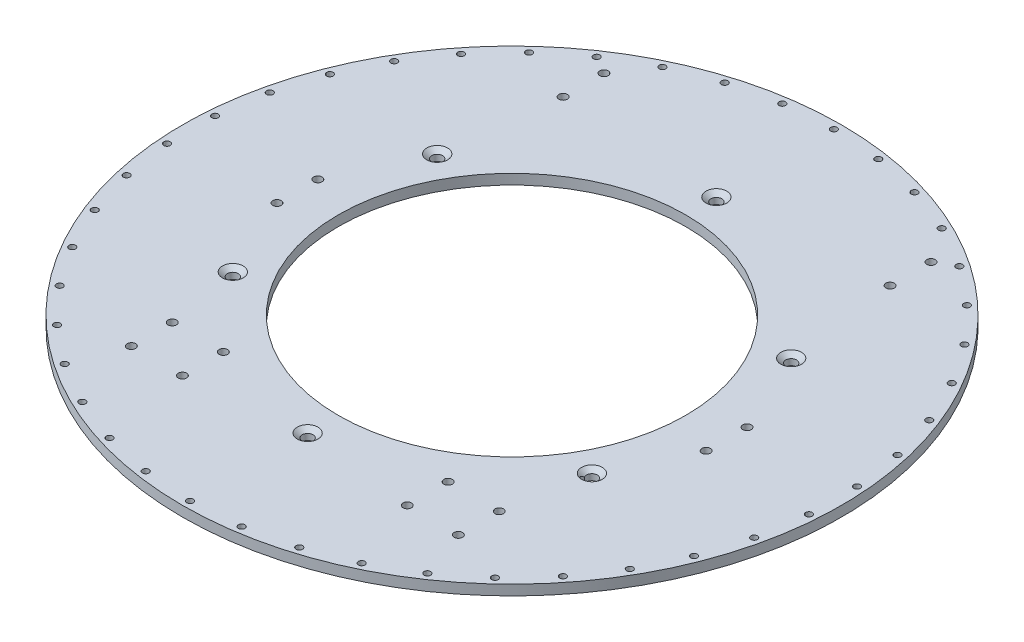
from build123d import *

# Parameters (mm, degrees)
SKETCH1_R                                           = 196.85
SKETCH1_R_2                                         = 107.95
SKETCH1_R_3                                         = 2.6289
SKETCH1_R_4                                         = 3.175
BOSS_EXTRUDE1_DEPTH                                 = 6.35
SKETCH3_R                                           = 204.7875
SKETCH3_R_2                                         = 196.85
BOSS_EXTRUDE2_DEPTH                                 = 6.35
CSK_FOR_1_4_FLAT_HEAD_MACHINE_SCREW_100_D           = 6.7564
CSK_FOR_1_4_FLAT_HEAD_MACHINE_SCREW_100_DEPTH       = 25.4
CSK_FOR_1_4_FLAT_HEAD_MACHINE_SCREW_100_CSINK_D     = 12.8778
CSK_FOR_1_4_FLAT_HEAD_MACHINE_SCREW_100_CSINK_ANGLE = 100
CSK_FOR_1_4_FLAT_HEAD_MACHINE_SCREW_100_TIP         = 2.029827343
SKETCH10_R                                          = 2.0193
CUT_EXTRUDE1_DEPTH                                  = 7.3500001


with BuildPart() as part:
    # Sketch1 → Boss-Extrude1 (new body)
    with BuildSketch(Plane(origin=(0, 0, 0), x_dir=(1, 0, 0), z_dir=(0, 1, 0))):
        Circle(SKETCH1_R)
        Circle(SKETCH1_R_2, mode=Mode.SUBTRACT)
        with Locations((69.85, -109.5375)):
            Circle(SKETCH1_R_3, mode=Mode.SUBTRACT)
        with Locations((69.85, -134.9375)):
            Circle(SKETCH1_R_3, mode=Mode.SUBTRACT)
        with Locations((101.6, -109.5375)):
            Circle(SKETCH1_R_3, mode=Mode.SUBTRACT)
        with Locations((101.6, -134.9375)):
            Circle(SKETCH1_R_3, mode=Mode.SUBTRACT)
        with Locations((101.6, 133.35)):
            Circle(SKETCH1_R_3, mode=Mode.SUBTRACT)
        with Locations((101.6, 158.75)):
            Circle(SKETCH1_R_3, mode=Mode.SUBTRACT)
        with Locations((133.35, -12.7)):
            Circle(SKETCH1_R_3, mode=Mode.SUBTRACT)
        with Locations((133.35, 12.7)):
            Circle(SKETCH1_R_3, mode=Mode.SUBTRACT)
        with Locations((-69.85, -134.9375)):
            Circle(SKETCH1_R_3, mode=Mode.SUBTRACT)
        with Locations((-101.6, -134.9375)):
            Circle(SKETCH1_R_3, mode=Mode.SUBTRACT)
        with Locations((-101.6, -109.5375)):
            Circle(SKETCH1_R_3, mode=Mode.SUBTRACT)
        with Locations((-69.85, -109.5375)):
            Circle(SKETCH1_R_3, mode=Mode.SUBTRACT)
        with Locations((-133.35, -12.7)):
            Circle(SKETCH1_R_3, mode=Mode.SUBTRACT)
        with Locations((-133.35, 12.7)):
            Circle(SKETCH1_R_3, mode=Mode.SUBTRACT)
        with Locations((-101.6, 158.75)):
            Circle(SKETCH1_R_3, mode=Mode.SUBTRACT)
        with Locations((-101.6, 133.35)):
            Circle(SKETCH1_R_3, mode=Mode.SUBTRACT)
        with Locations((0, 127)):
            Circle(SKETCH1_R_4, mode=Mode.SUBTRACT)
        with Locations((109.985226281, 63.5)):
            Circle(SKETCH1_R_4, mode=Mode.SUBTRACT)
        with Locations((109.985226281, -63.5)):
            Circle(SKETCH1_R_4, mode=Mode.SUBTRACT)
        with Locations((0, -127)):
            Circle(SKETCH1_R_4, mode=Mode.SUBTRACT)
        with Locations((-109.985226281, -63.5)):
            Circle(SKETCH1_R_4, mode=Mode.SUBTRACT)
        with Locations((-109.985226281, 63.5)):
            Circle(SKETCH1_R_4, mode=Mode.SUBTRACT)
    extrude(amount=BOSS_EXTRUDE1_DEPTH)

    # Sketch3 → Boss-Extrude2 (add)
    with BuildSketch(Plane(origin=(0, 6.35, 0), x_dir=(1, 0, 0), z_dir=(0, 1, 0))):
        Circle(SKETCH3_R)
        Circle(SKETCH3_R_2, mode=Mode.SUBTRACT)
    extrude(amount=-BOSS_EXTRUDE2_DEPTH)

    # CSK for 1/4 Flat Head Machine Screw (100)1
    with Locations(Plane(origin=(0, 6.35, 0), x_dir=(1, 0, 0), z_dir=(0, 1, 0))):
        with Locations((0, 127), (-109.985226281, 63.5), (-109.985226281, -63.5), (0, -127), (109.985226281, -60.325), (109.985226281, 63.5)):
            CounterSinkHole(CSK_FOR_1_4_FLAT_HEAD_MACHINE_SCREW_100_D / 2, CSK_FOR_1_4_FLAT_HEAD_MACHINE_SCREW_100_CSINK_D / 2, depth=CSK_FOR_1_4_FLAT_HEAD_MACHINE_SCREW_100_DEPTH, counter_sink_angle=CSK_FOR_1_4_FLAT_HEAD_MACHINE_SCREW_100_CSINK_ANGLE)
            with Locations((0, 0, -(CSK_FOR_1_4_FLAT_HEAD_MACHINE_SCREW_100_DEPTH + CSK_FOR_1_4_FLAT_HEAD_MACHINE_SCREW_100_TIP / 2))):  # 118° drill point
                Cone(0, CSK_FOR_1_4_FLAT_HEAD_MACHINE_SCREW_100_D / 2, CSK_FOR_1_4_FLAT_HEAD_MACHINE_SCREW_100_TIP, mode=Mode.SUBTRACT)

    # Sketch10 → Cut-Extrude1 (cut, through all)
    with BuildSketch(Plane(origin=(0, 6.35, 0), x_dir=(1, 0, 0), z_dir=(0, 1, 0))):
        with Locations((0, 200.025)):
            Circle(SKETCH10_R)
        with Locations((29.812179292, 197.790886016)):
            Circle(SKETCH10_R)
        with Locations((58.958403762, 191.138450477)):
            Circle(SKETCH10_R)
        with Locations((86.787594917, 180.216297802)):
            Circle(SKETCH10_R)
        with Locations((112.678094614, 165.268410833)):
            Circle(SKETCH10_R)
        with Locations((136.051551873, 146.628700663)):
            Circle(SKETCH10_R)
        with Locations((156.385842281, 124.713547617)):
            Circle(SKETCH10_R)
        with Locations((173.226731392, 100.0125)):
            Circle(SKETCH10_R)
        with Locations((186.198021573, 73.077338399)):
            Circle(SKETCH10_R)
        with Locations((195.009955634, 44.509749815)):
            Circle(SKETCH10_R)
        with Locations((199.465689531, 14.94788697)):
            Circle(SKETCH10_R)
        with Locations((199.465689531, -14.94788697)):
            Circle(SKETCH10_R)
        with Locations((195.009955634, -44.509749815)):
            Circle(SKETCH10_R)
        with Locations((186.198021573, -73.077338399)):
            Circle(SKETCH10_R)
        with Locations((173.226731392, -100.0125)):
            Circle(SKETCH10_R)
        with Locations((156.385842281, -124.713547617)):
            Circle(SKETCH10_R)
        with Locations((136.051551873, -146.628700663)):
            Circle(SKETCH10_R)
        with Locations((112.678094614, -165.268410833)):
            Circle(SKETCH10_R)
        with Locations((86.787594917, -180.216297802)):
            Circle(SKETCH10_R)
        with Locations((58.958403762, -191.138450477)):
            Circle(SKETCH10_R)
        with Locations((29.812179292, -197.790886016)):
            Circle(SKETCH10_R)
        with Locations((0, -200.025)):
            Circle(SKETCH10_R)
        with Locations((-29.812179292, -197.790886016)):
            Circle(SKETCH10_R)
        with Locations((-58.958403762, -191.138450477)):
            Circle(SKETCH10_R)
        with Locations((-86.787594917, -180.216297802)):
            Circle(SKETCH10_R)
        with Locations((-112.678094614, -165.268410833)):
            Circle(SKETCH10_R)
        with Locations((-136.051551873, -146.628700663)):
            Circle(SKETCH10_R)
        with Locations((-156.385842281, -124.713547617)):
            Circle(SKETCH10_R)
        with Locations((-173.226731392, -100.0125)):
            Circle(SKETCH10_R)
        with Locations((-186.198021573, -73.077338399)):
            Circle(SKETCH10_R)
        with Locations((-195.009955634, -44.509749815)):
            Circle(SKETCH10_R)
        with Locations((-199.465689531, -14.94788697)):
            Circle(SKETCH10_R)
        with Locations((-199.465689531, 14.94788697)):
            Circle(SKETCH10_R)
        with Locations((-195.009955634, 44.509749815)):
            Circle(SKETCH10_R)
        with Locations((-186.198021573, 73.077338399)):
            Circle(SKETCH10_R)
        with Locations((-173.226731392, 100.0125)):
            Circle(SKETCH10_R)
        with Locations((-156.385842281, 124.713547617)):
            Circle(SKETCH10_R)
        with Locations((-136.051551873, 146.628700663)):
            Circle(SKETCH10_R)
        with Locations((-112.678094614, 165.268410833)):
            Circle(SKETCH10_R)
        with Locations((-86.787594917, 180.216297802)):
            Circle(SKETCH10_R)
        with Locations((-58.958403762, 191.138450477)):
            Circle(SKETCH10_R)
        with Locations((-29.812179292, 197.790886016)):
            Circle(SKETCH10_R)
    extrude(amount=-CUT_EXTRUDE1_DEPTH, mode=Mode.SUBTRACT)


solid = part.part
